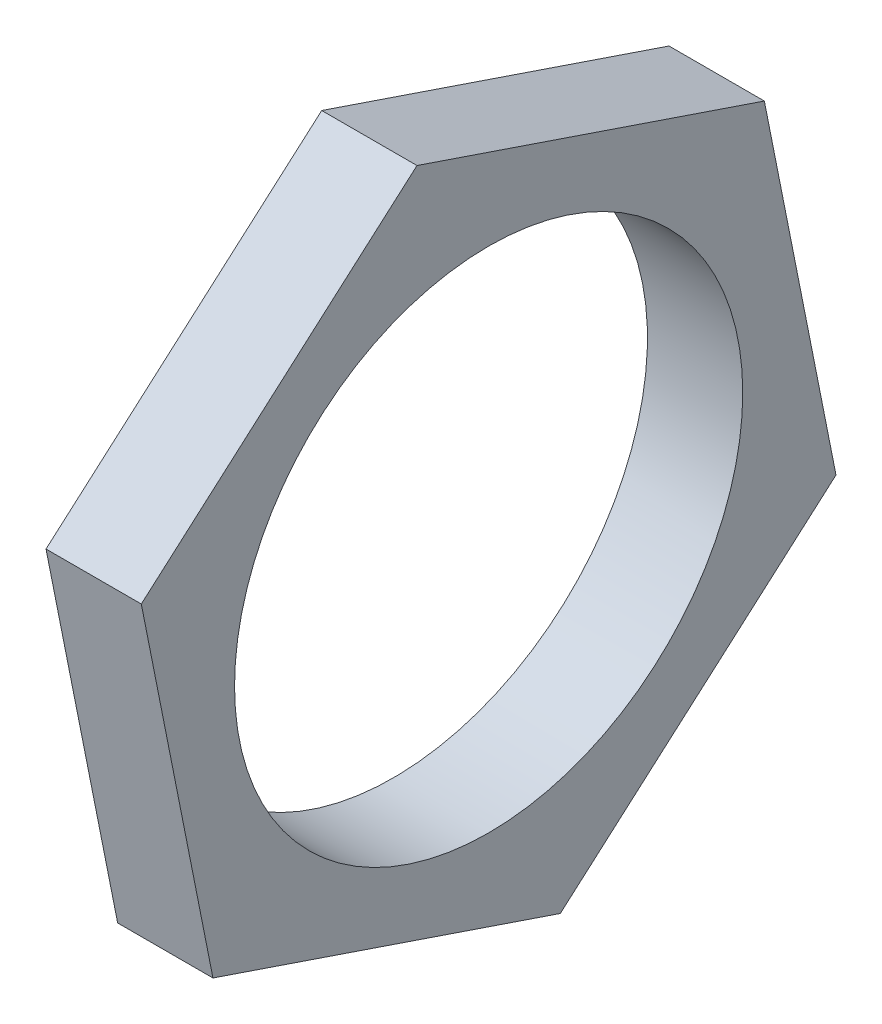
from build123d import *

# Parameters (mm, degrees)
BOSS_EXTRUDE1_DEPTH = 3
CUT_EXTRUDE1_REACH  = 5
SKETCH3_R           = 8


with BuildPart() as part:
    # Sketch2 → Boss-Extrude1 (new body)
    with BuildSketch(Plane(origin=(0, 0, 0), x_dir=(0, 0, -1), z_dir=(1, 0, 0))):
        Polygon((8.679494794, 7.615753637), (-2.255688722, 11.324539802), (-10.935183515, 3.708786165), (-8.679494794, -7.615753637), (2.255688722, -11.324539802), (10.935183515, -3.708786165), align=None)
    extrude(amount=BOSS_EXTRUDE1_DEPTH)

    # Sketch3 → Cut-Extrude1 (cut, up to next)
    with BuildSketch(Plane.ZY, mode=Mode.PRIVATE) as cut_extrude1_sk1:
        Circle(SKETCH3_R)
    cut_extrude1_tool1 = extrude(cut_extrude1_sk1.sketch, amount=-CUT_EXTRUDE1_REACH, mode=Mode.PRIVATE) & part.part
    add(cut_extrude1_tool1.solids().sort_by_distance((0, 0, 0))[0], mode=Mode.SUBTRACT)


solid = part.part
